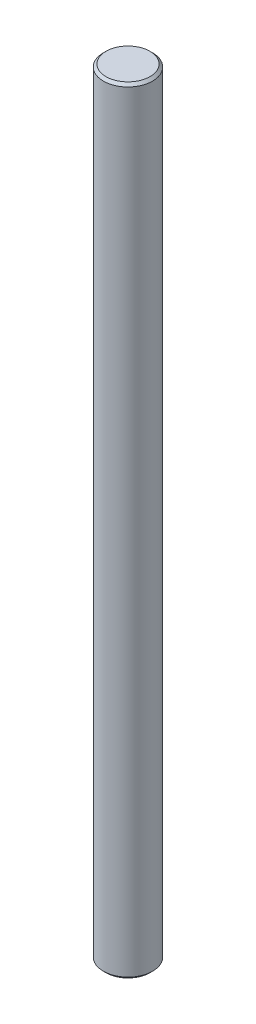
from build123d import *

# Parameters (mm, degrees)
BOSS_EXTRUDE1_DEPTH = 76.2
CHAMFER1_SIZE       = 0.254


with BuildPart() as part:
    # Sketch1 → Boss-Extrude1 (new body)
    with BuildSketch(Plane(origin=(0, 0, 0), x_dir=(1, 0, 0), z_dir=(0, 1, 0))):
        with BuildLine():
            ThreePointArc((2.091397583, 1.203588447), (0, 2.413), (-2.091397583, 1.203588447))
            Line((-2.091397583, 1.203588447), (2.091397583, 1.203588447))
        make_face()
        with BuildLine():
            Line((2.091397583, 1.203588447), (-2.091397583, 1.203588447))
            ThreePointArc((-2.091397583, 1.203588447), (-0.622907149, -2.33121335), (2.413, 0))
            ThreePointArc((2.413, 0), (2.33121335, 0.622907149), (2.091397583, 1.203588447))
        make_face()
    extrude(amount=BOSS_EXTRUDE1_DEPTH)

    # Chamfer1
    chamfer1_edges = [part.edges().sort_by_distance(p)[0] for p in [
        (-2.091397583, 0, 1.203588447),
        (-2.091397583, 76.2, 1.203588447),
    ]]
    chamfer(chamfer1_edges, length=CHAMFER1_SIZE)


solid = part.part
